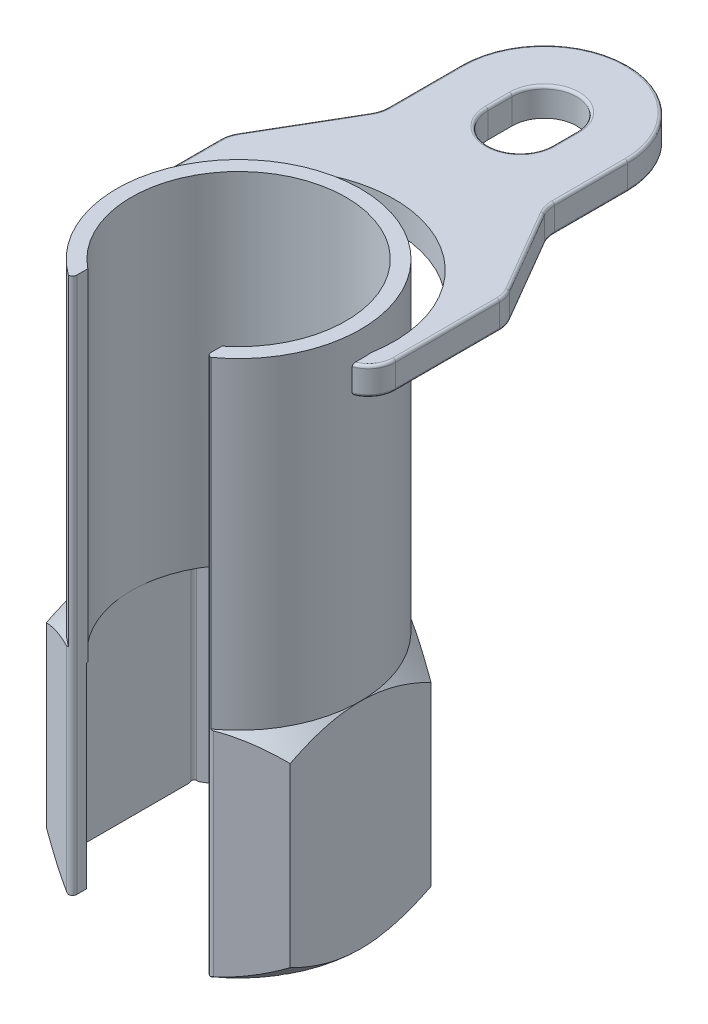
from build123d import *
from build123d.topology import SkipClean

# Parameters (mm, degrees)
EXTRUDE1_DEPTH     = 40
EXTRUDE2_DEPTH     = 60
SKETCH8_OUTSIDE_W  = 273.23
SKETCH8_OUTSIDE_H  = 273.047
SKETCH8_OUTSIDE_R  = 22.733166849
CUT_EXTRUDE4_DEPTH = 101
CUT_EXTRUDE4_DRAFT = -45
SKETCH19_OUTSIDE_W = 153.23
SKETCH19_OUTSIDE_H = 153.047
SKETCH19_OUTSIDE_R = 22.733066849
CUT_EXTRUDE6_DEPTH = 41
CUT_EXTRUDE6_DRAFT = -45
CUT_EXTRUDE9_START = -36.483067
CUT_EXTRUDE9_DEPTH = 36.483075
FILLET1_R          = 0.8
EXTRUDE7_DEPTH     = 5.2
CUT_EXTRUDE8_REACH = 97.2
FILLET4_R          = 0.5


with BuildPart() as part:
    # Sketch1 → Extrude1 (new body)
    with BuildSketch(Plane(origin=(0, 0, 0), x_dir=(1, 0, 0), z_dir=(0, 1, 0))):
        with BuildLine():
            Line((-12.5, -15.612494996), (-12.5, -19.033121635))
            Line((-12.5, -19.033121635), (-22.733166849, -13.125))
            Line((-22.733166849, -13.125), (-22.733166849, 13.125))
            Line((-22.733166849, 13.125), (0, 26.25))
            Line((0, 26.25), (22.733166849, 13.125))
            Line((22.733166849, 13.125), (22.733166849, -13.125))
            Line((22.733166849, -13.125), (12.5, -19.033121635))
            Line((12.5, -19.033121635), (12.5, -15.612494996))
            ThreePointArc((12.5, -15.612494996), (0, 20), (-12.5, -15.612494996))
        make_face()
    extrude(amount=EXTRUDE1_DEPTH)

    # Sketch3 → Extrude2 (add)
    with BuildSketch(Plane(origin=(0, 40, 0), x_dir=(-1, 0, 0), z_dir=(0, 1, 0))):
        with BuildLine():
            Line((-12.5, 18.98795219), (-12.5, 15.612494996))
            ThreePointArc((-12.5, 15.612494996), (0, -20), (12.5, 15.612494996))
            Line((12.5, 15.612494996), (12.5, 18.98795219))
            ThreePointArc((12.5, 18.98795219), (0, -22.733066849), (-12.5, 18.98795219))
        make_face()
    extrude(amount=EXTRUDE2_DEPTH)


with BuildPart() as cut_extrude4_tool:
    # Sketch8 outside → Cut-Extrude4 (with draft: the straight prism first)
    with BuildSketch(Plane.XZ):
        with Locations((0, -3.6085)):
            Rectangle(SKETCH8_OUTSIDE_W, SKETCH8_OUTSIDE_H)
        Circle(SKETCH8_OUTSIDE_R, mode=Mode.SUBTRACT)
    extrude(amount=-CUT_EXTRUDE4_DEPTH)
    # Cut-Extrude4: the draft: its side faces are tilted about the plane it starts from
    cut_extrude4_sides = [cut_extrude4_tool.faces().sort_by_distance(p)[0] for p in [
        (0, 50.5, -140.132),
        (136.615, 50.5, -3.6085),
        (0, 50.5, 132.915),
        (-136.615, 50.5, -3.6085),
        (-22.733166849, 50.5, 0),
    ]]
    draft(cut_extrude4_sides, Plane.XZ, CUT_EXTRUDE4_DRAFT)


with BuildPart() as part_1:
    add(part.part)

    # Cut-Extrude4: cut by cut_extrude4_tool
    add(cut_extrude4_tool.part, mode=Mode.SUBTRACT)


with BuildPart() as cut_extrude6_tool:
    # Sketch19 outside → Cut-Extrude6 (with draft: the straight prism first)
    with BuildSketch(Plane(origin=(0, 40, 0), x_dir=(-1, 0, 0), z_dir=(0, 1, 0))):
        with Locations((0, -3.6085)):
            Rectangle(SKETCH19_OUTSIDE_W, SKETCH19_OUTSIDE_H)
        Circle(SKETCH19_OUTSIDE_R, mode=Mode.SUBTRACT)
    extrude(amount=-CUT_EXTRUDE6_DEPTH)
    # Cut-Extrude6: the draft: its side faces are tilted about the plane it starts from
    cut_extrude6_sides = [cut_extrude6_tool.faces().sort_by_distance(p)[0] for p in [
        (0, 19.5, -80.132),
        (-76.615, 19.5, -3.6085),
        (0, 19.5, 72.915),
        (76.615, 19.5, -3.6085),
        (22.733066849, 19.5, 0),
    ]]
    draft(cut_extrude6_sides, Plane(origin=(0, 40, 0), x_dir=(-1, 0, 0), z_dir=(0, 1, 0)), CUT_EXTRUDE6_DRAFT)


with BuildPart() as part_2:
    add(part_1.part)

    # Cut-Extrude6: cut by cut_extrude6_tool
    add(cut_extrude6_tool.part, mode=Mode.SUBTRACT)

    # Sketch26 → Cut-Extrude9 (cut)
    with BuildSketch(Plane.XZ.offset(CUT_EXTRUDE9_START)):
        Polygon((-20, -11.547005384), (0, -23.094010768), (20, -11.547005384), (20, 11.547005384), (0, 23.094010768), (-20, 11.547005384), align=None)
    extrude(amount=CUT_EXTRUDE9_DEPTH, mode=Mode.SUBTRACT)

    # Fillet1
    fillet1_edges = [part_2.edges().sort_by_distance(p)[0] for p in [
        (-20, 18.421955459, -11.547005384),
        (-20, 18.421955459, 11.547005384),
        (20, 18.421955459, 11.547005384),
        (20, 18.421955459, -11.547005384),
        (-12.5, 19.99995, 19.033121635),
        (12.5, 19.99995, 19.033121635),
        (0, 18.421955459, -23.094010768),
    ]]
    fillet(fillet1_edges, radius=FILLET1_R)

    # Sketch16 → Extrude7 (add)
    with BuildSketch(Plane(origin=(0, 90, 0), x_dir=(-1, 0, 0), z_dir=(0, 1, 0))):
        with BuildLine():
            Line((-15.5, -57), (-15.5, -43.378780621))
            ThreePointArc((-15.5, -43.378780621), (-15.676744511, -42.047782727), (-16.194727605, -40.809038391))
            Line((-16.194727605, -40.809038391), (-25.305272395, -25.190961609))
            ThreePointArc((-25.305272395, -25.190961609), (-25.823255489, -23.952217273), (-26, -22.621219379))
            Line((-26, -22.621219379), (-26, -3.277974136))
            ThreePointArc((-26, -3.277974136), (-25.08962886, -0.369880256), (-22.683525484, 1.5))
            ThreePointArc((-22.683525484, 1.5), (0, -22.733066849), (22.683525484, 1.5))
            ThreePointArc((22.683525484, 1.5), (25.08962886, -0.369880256), (26, -3.277974136))
            Line((26, -3.277974136), (26, -22.621219379))
            ThreePointArc((26, -22.621219379), (25.823255489, -23.952217273), (25.305272395, -25.190961609))
            Line((25.305272395, -25.190961609), (16.194727605, -40.809038391))
            ThreePointArc((16.194727605, -40.809038391), (15.676744511, -42.047782727), (15.5, -43.378780621))
            Line((15.5, -43.378780621), (15.5, -57))
            ThreePointArc((15.5, -57), (0, -72.5), (-15.5, -57))
        make_face()
    extrude(amount=EXTRUDE7_DEPTH)

    # Sketch25 → Cut-Extrude8 (cut, up to next)
    with BuildSketch(Plane.XZ.offset(-95.2), mode=Mode.PRIVATE) as cut_extrude8_sk1:
        with BuildLine():
            Line((-6, -57), (-6, -52.5))
            ThreePointArc((-6, -52.5), (0, -46.5), (6, -52.5))
            Line((6, -52.5), (6, -57))
            ThreePointArc((6, -57), (0, -63), (-6, -57))
        make_face()
    cut_extrude8_tool1 = extrude(cut_extrude8_sk1.sketch, amount=CUT_EXTRUDE8_REACH, mode=Mode.PRIVATE) & part_2.part
    add(cut_extrude8_tool1.solids().sort_by_distance((0, 95.2, -54.75))[0], mode=Mode.SUBTRACT)
    # Sketch25 → Cut-Extrude8 (cut, up to next)
    with BuildSketch(Plane.XZ.offset(-95.2), mode=Mode.PRIVATE) as cut_extrude8_sk2:
        with BuildLine():
            ThreePointArc((22.644918379, -2), (0, -22.733066849), (-22.644918379, -2))
            ThreePointArc((-22.644918379, -2), (0, -28.995484956), (22.644918379, -2))
        make_face()
    cut_extrude8_tool2 = extrude(cut_extrude8_sk2.sketch, amount=CUT_EXTRUDE8_REACH, mode=Mode.PRIVATE) & part_2.part
    add(cut_extrude8_tool2.solids().sort_by_distance((0, 95.2, -23.266352))[0], mode=Mode.SUBTRACT)

    # Fillet4
    fillet4_edges = [part_2.edges().sort_by_distance(p)[0] for p in [
        (-25.08962886, 90, -0.369880256),
        (25.08962886, 90, -0.369880256),
        (26, 90, -12.949596758),
        (25.823255489, 90, -23.952217273),
        (20.75, 90, -33),
        (15.676744511, 90, -42.047782727),
        (15.5, 90, -50.18939031),
        (0, 90, -72.5),
        (-15.5, 90, -50.18939031),
        (-15.676744511, 90, -42.047782727),
        (-20.75, 90, -33),
        (-25.823255489, 90, -23.952217273),
        (-26, 90, -12.949596758),
        (-25.08962886, 95.2, -0.369880256),
        (25.08962886, 95.2, -0.369880256),
        (26, 95.2, -12.949596758),
        (25.823255489, 95.2, -23.952217273),
        (20.75, 95.2, -33),
        (15.676744511, 95.2, -42.047782727),
        (15.5, 95.2, -50.18939031),
        (0, 95.2, -72.5),
        (-15.5, 95.2, -50.18939031),
        (-15.676744511, 95.2, -42.047782727),
        (-20.75, 95.2, -33),
        (-25.823255489, 95.2, -23.952217273),
        (-26, 95.2, -12.949596758),
        (0, 95.2, -63),
        (6, 95.2, -54.75),
        (0, 95.2, -46.5),
        (-6, 95.2, -54.75),
    ]]
    fillet(fillet4_edges, radius=FILLET4_R)


solid = part_2.part
